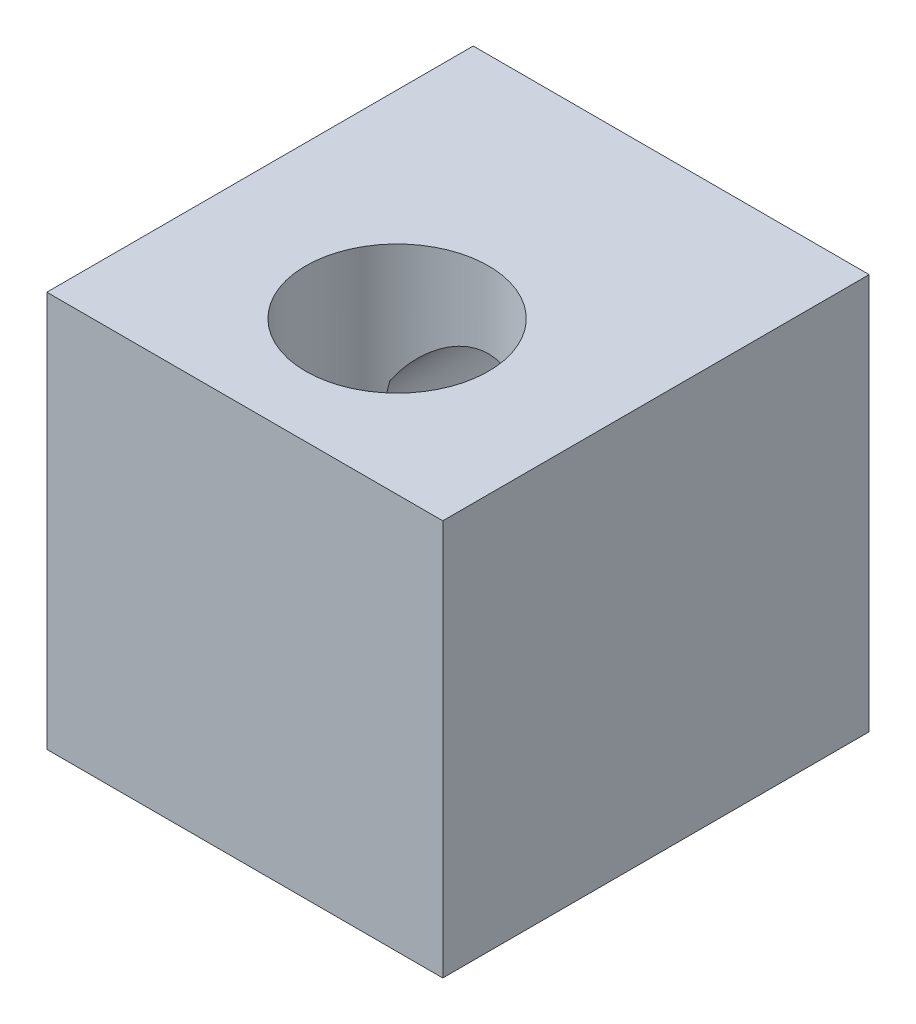
from build123d import *

# Parameters (mm, degrees)
SKETCH1_W                 = 13
SKETCH1_H                 = 13
BOSS_EXTRUDE1_DEPTH       = 14
F_6_0MM_DOWEL_HOLE1_D     = 6
F_6_0MM_DOWEL_HOLE1_DEPTH = 13
M6X1_0_TAPPED_HOLE6_D     = 5
M6X1_0_TAPPED_HOLE6_DEPTH = 7
M6X1_0_TAPPED_HOLE6_TIP   = 1.502151548


with BuildPart() as part:
    # Sketch1 → Boss-Extrude1 (new body)
    with BuildSketch(Plane.XY):
        Rectangle(SKETCH1_W, SKETCH1_H)
    extrude(amount=BOSS_EXTRUDE1_DEPTH)

    # Ø6.0mm Dowel Hole1
    with Locations(Plane(origin=(0, 6.5, 0), x_dir=(1, 0, 0), z_dir=(0, 1, 0))):
        with Locations((0, -9)):
            Hole(F_6_0MM_DOWEL_HOLE1_D / 2, depth=F_6_0MM_DOWEL_HOLE1_DEPTH)

    # M6x1.0 Tapped Hole6
    with Locations(Plane(origin=(0, 0, 0), x_dir=(-1, 0, 0), z_dir=(0, 0, -1))):
        with Locations((0, 1.5)):
            Hole(M6X1_0_TAPPED_HOLE6_D / 2, depth=M6X1_0_TAPPED_HOLE6_DEPTH)
            with Locations((0, 0, -(M6X1_0_TAPPED_HOLE6_DEPTH + M6X1_0_TAPPED_HOLE6_TIP / 2))):  # 118° drill point
                Cone(0, M6X1_0_TAPPED_HOLE6_D / 2, M6X1_0_TAPPED_HOLE6_TIP, mode=Mode.SUBTRACT)


solid = part.part
